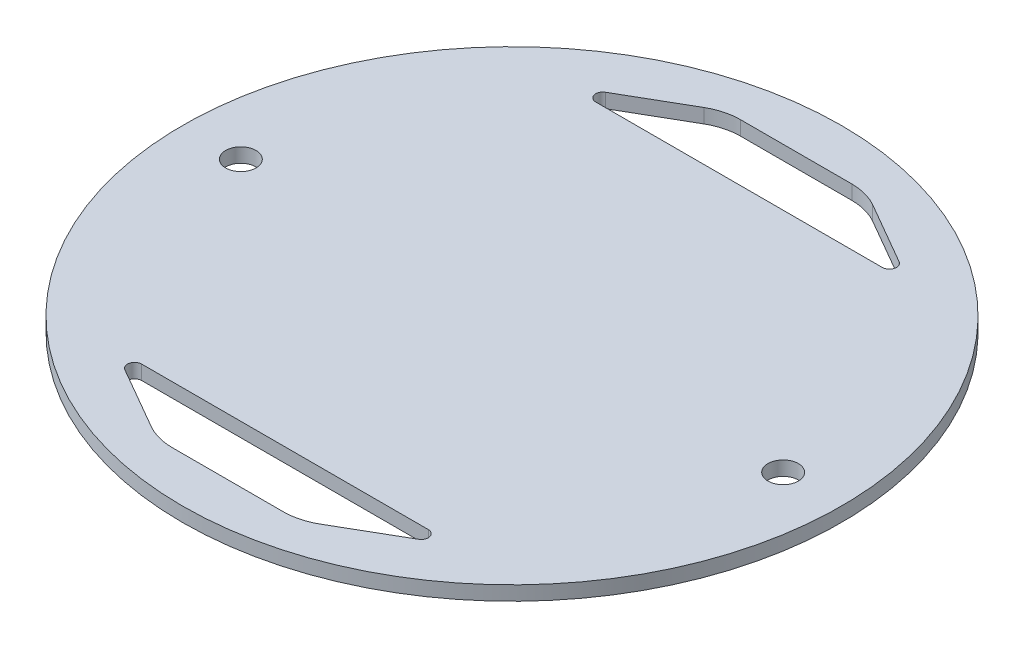
from build123d import *

# Parameters (mm, degrees)
SKETCH2_R               = 73.3171
BOSS_EXTRUDE1_DEPTH     = 3.175
F_1_4_CLEARANCE_HOLE1_D = 6.7564
CUT_EXTRUDE1_START      = -4.175
CUT_EXTRUDE1_DEPTH      = 5.175
FILLET1_R               = 12.7
FILLET2_R               = 1.5875
FILLET1_OF_MIRROR1_R    = 12.7
FILLET2_OF_MIRROR1_R    = 1.5875


with BuildPart() as part:
    # Sketch2 → Boss-Extrude1 (new body)
    with BuildSketch(Plane(origin=(0, 0, 0), x_dir=(1, 0, 0), z_dir=(0, 1, 0))):
        Circle(SKETCH2_R)
    extrude(amount=BOSS_EXTRUDE1_DEPTH)

    # 1/4 Clearance Hole1 (through all)
    with Locations(Plane(origin=(0, 3.175, 0), x_dir=(1, 0, 0), z_dir=(0, 1, 0))):
        with Locations((-60.325, 0), (60.325, 0)):
            Hole(F_1_4_CLEARANCE_HOLE1_D / 2)

    # Sketch5 → Cut-Extrude1 (cut)
    with BuildSketch(Plane(origin=(0, 3.175, 0), x_dir=(1, 0, 0), z_dir=(0, 1, 0)).offset(CUT_EXTRUDE1_START)):
        Polygon((0, 63.2), (-15.802954744, 63.2), (-37.8, 50.5), (0, 50.5), align=None)
        Polygon((15.802954744, 63.2), (0, 63.2), (0, 50.5), (37.8, 50.5), align=None)
    cut_extrude1 = extrude(amount=CUT_EXTRUDE1_DEPTH, mode=Mode.SUBTRACT)

    # Fillet1
    fillet1_edges = [part.edges().sort_by_distance(p)[0] for p in [
        (-15.802954744, 1.5875, -63.2),
        (15.802954744, 1.5875, -63.2),
    ]]
    fillet(fillet1_edges, radius=FILLET1_R)

    # Fillet2
    fillet2_edges = [part.edges().sort_by_distance(p)[0] for p in [
        (-37.8, 1.5875, -50.5),
        (37.8, 1.5875, -50.5),
    ]]
    fillet(fillet2_edges, radius=FILLET2_R)

    # Mirror1: Cut-Extrude1 across plane
    add(cut_extrude1.mirror(Plane.XY), mode=Mode.SUBTRACT)

    # Fillet1 of Mirror1
    fillet1_of_mirror1_edges = [part.edges().sort_by_distance(p)[0] for p in [
        (-15.802954744, 1.5875, 63.2),
        (15.802954744, 1.5875, 63.2),
    ]]
    fillet(fillet1_of_mirror1_edges, radius=FILLET1_OF_MIRROR1_R)

    # Fillet2 of Mirror1
    fillet2_of_mirror1_edges = [part.edges().sort_by_distance(p)[0] for p in [
        (-37.8, 1.5875, 50.5),
        (37.8, 1.5875, 50.5),
    ]]
    fillet(fillet2_of_mirror1_edges, radius=FILLET2_OF_MIRROR1_R)


solid = part.part
